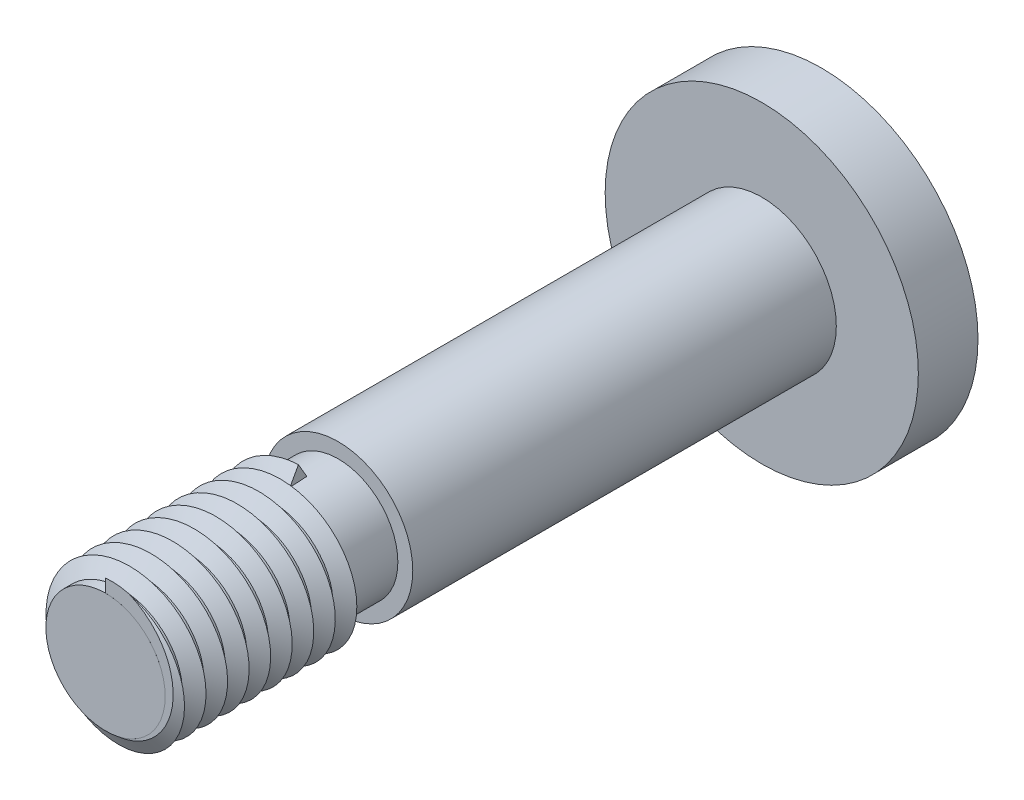
from build123d import *

# Parameters (mm, degrees)
SKETCH1_R           = 3.175
BOSS_EXTRUDE1_DEPTH = 27.94
SKETCH2_R           = 6.6675
BOSS_EXTRUDE2_DEPTH = 2.54
SKETCH3_R           = 3.175
SKETCH3_R_2         = 2.54
CUT_EXTRUDE1_DEPTH  = 9.906
SWEEP1_PITCH        = 0.917222222
SWEEP1_HEIGHT       = 8.255
SWEEP1_RADIUS       = 2.54
SWEEP1_START_ANGLE  = 90
SKETCH6_W           = 2.025979595
SKETCH6_H           = 0.581412662


with BuildPart() as part:
    # Sketch1 → Boss-Extrude1 (new body)
    with BuildSketch(Plane.XY):
        Circle(SKETCH1_R)
    extrude(amount=BOSS_EXTRUDE1_DEPTH)

    # Sketch2 → Boss-Extrude2 (add)
    with BuildSketch(Plane.XY):
        Circle(SKETCH2_R)
    extrude(amount=-BOSS_EXTRUDE2_DEPTH)

    # Sketch3 → Cut-Extrude1 (cut)
    with BuildSketch(Plane.XY.offset(27.94)):
        Circle(SKETCH3_R)
        Circle(SKETCH3_R_2, mode=Mode.SUBTRACT)
    extrude(amount=-CUT_EXTRUDE1_DEPTH, mode=Mode.SUBTRACT)


with BuildPart() as body_2:
    # Sweep1: sweep along a helix
    with BuildLine() as sweep1_path:
        add(Helix(SWEEP1_PITCH, SWEEP1_HEIGHT, SWEEP1_RADIUS, center=(0, 0, 27.94), direction=(0, 0, -1), mode=Mode.PRIVATE).rotate(Axis((0, 0, 27.94), (0, 0, -1)), SWEEP1_START_ANGLE))
    # Sketch5 → Sweep1 (sweep)
    with BuildSketch(Plane(origin=(0, 2.54, 19.685), x_dir=(-0.057377934, 0, -0.998352529), z_dir=(0.998352529, 0, -0.057377934))):
        Polygon((-0.42661441, 0), (0.33538559, 0), (-0.04561441, 0.635), align=None)
    sweep(path=sweep1_path.line, is_frenet=True)

    # Sketch6 → Cut-Revolve1 (revolve, cut)
    with BuildSketch(Plane(origin=(0, 0, 0), x_dir=(1, 0, 0), z_dir=(0, 1, 0))):
        with Locations((2.279143785, -28.230706331)):
            Rectangle(SKETCH6_W, SKETCH6_H)
    revolve(axis=Axis((0, 0, 0), (0, 0, 1)), mode=Mode.SUBTRACT)


solid = Compound([part.part, body_2.part])
